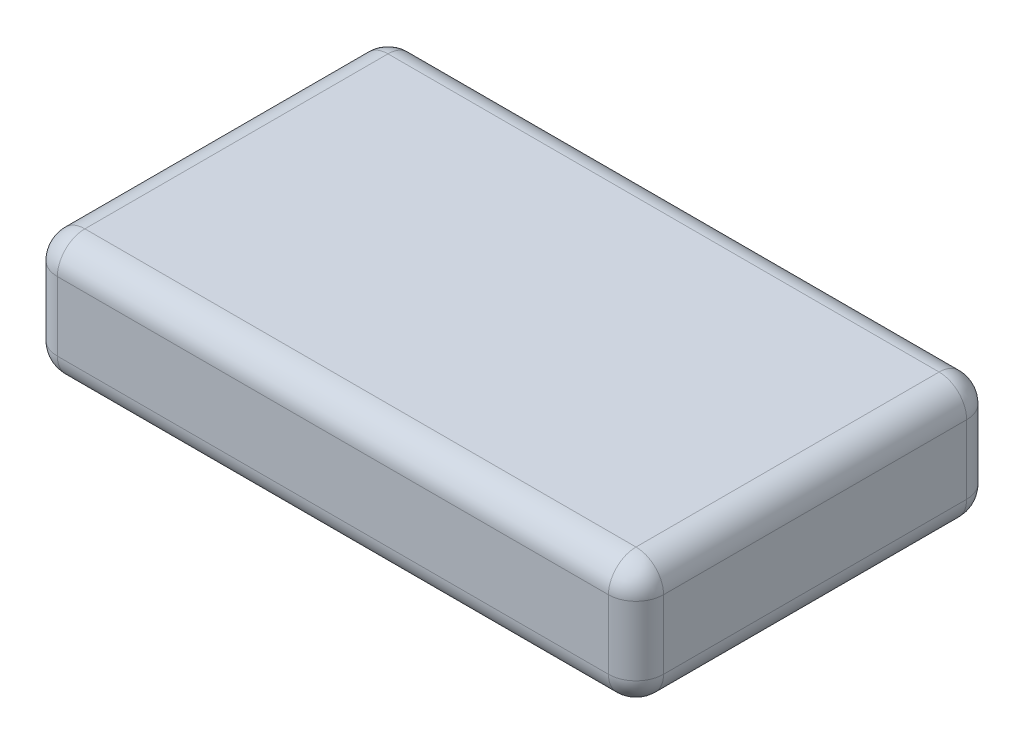
from build123d import *

# Parameters (mm, degrees)
SCHIZZO1_W                   = 44
SCHIZZO1_H                   = 26
ESTRUSIONE_ESTRUSIONE1_DEPTH = 9
RACCORDO1_R                  = 2


with BuildPart() as part:
    # Schizzo1 → Estrusione-Estrusione1 (new body)
    with BuildSketch(Plane(origin=(0, 0, 0), x_dir=(1, 0, 0), z_dir=(0, 1, 0))):
        Rectangle(SCHIZZO1_W, SCHIZZO1_H)
    extrude(amount=ESTRUSIONE_ESTRUSIONE1_DEPTH)

    # Raccordo1
    raccordo1_edges = [part.edges().sort_by_distance(p)[0] for p in [
        (22, 9, 0),
        (0, 9, -13),
        (-22, 9, 0),
        (0, 0, -13),
        (22, 0, 0),
        (0, 0, 13),
        (-22, 0, 0),
        (-22, 4.5, -13),
        (22, 4.5, -13),
        (22, 4.5, 13),
        (-22, 4.5, 13),
        (0, 9, 13),
    ]]
    fillet(raccordo1_edges, radius=RACCORDO1_R)


solid = part.part
